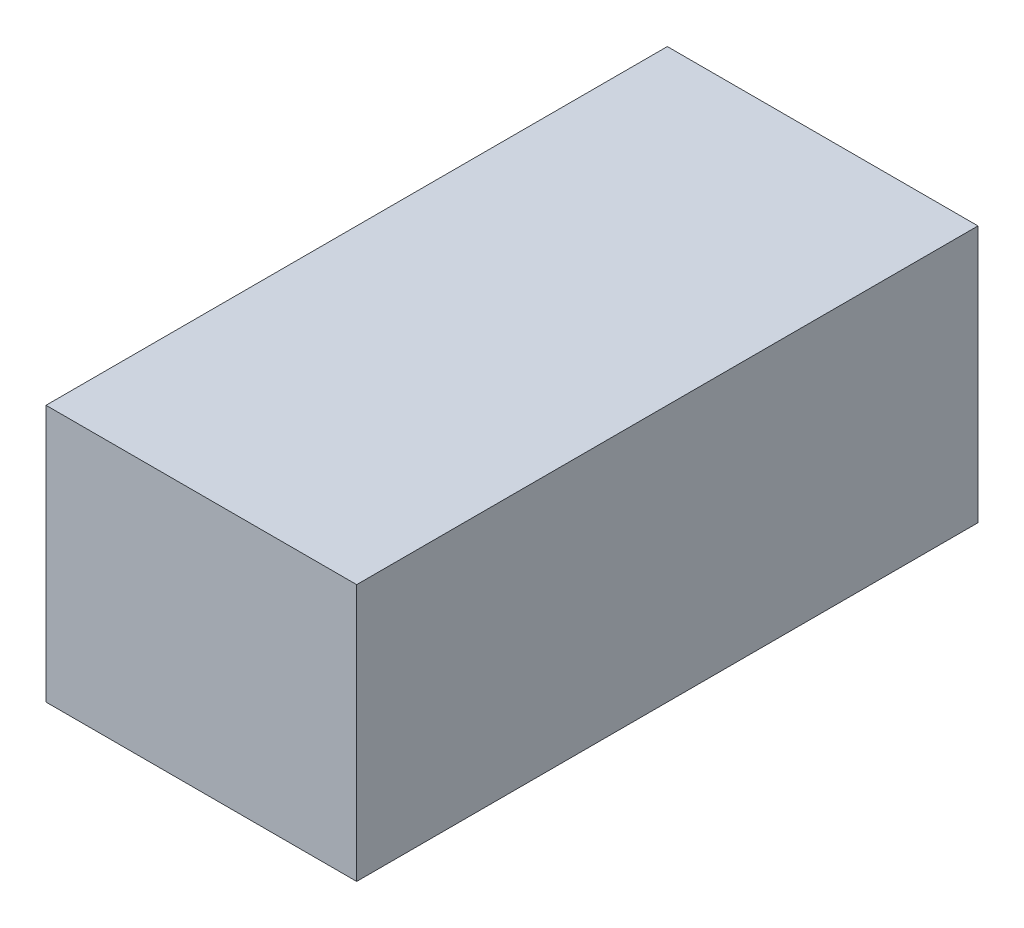
from build123d import *

# Parameters (mm, degrees)
ESQUISSE1_W        = 0.5
ESQUISSE1_H        = 0.413726181
BOSS_EXTRU_1_DEPTH = 1


with BuildPart() as part:
    # Esquisse1 → Boss.-Extru.1 (new body)
    with BuildSketch(Plane.XY):
        with Locations((-0.55, 2.59313691)):
            Rectangle(ESQUISSE1_W, ESQUISSE1_H)
    extrude(amount=BOSS_EXTRU_1_DEPTH)


solid = part.part
